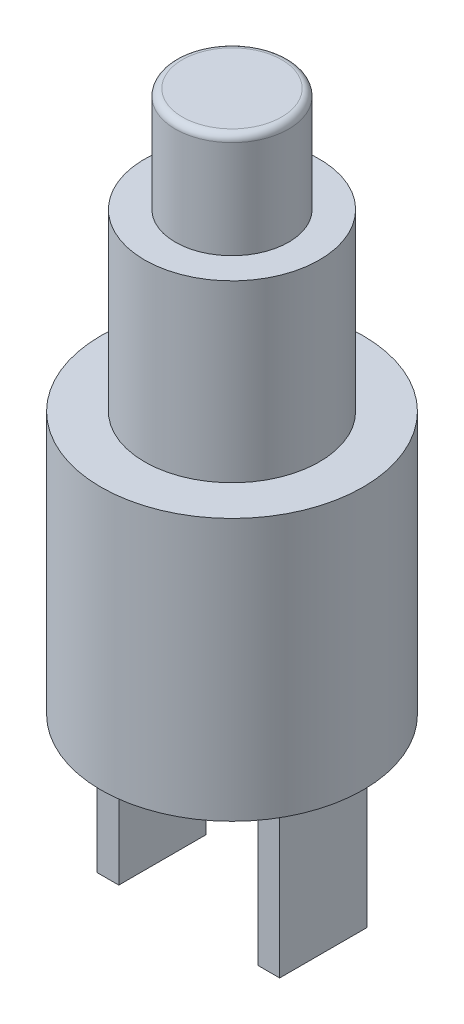
from build123d import *

# Parameters (mm, degrees)
SKETCH1_R           = 4.7625
BOSS_EXTRUDE1_DEPTH = 9.525
SKETCH2_R           = 3.175
BOSS_EXTRUDE2_DEPTH = 6.35
SKETCH3_R           = 2.0574
BOSS_EXTRUDE3_DEPTH = 3.81
SKETCH4_W           = 0.79375
SKETCH4_H           = 3.175
BOSS_EXTRUDE4_DEPTH = 5.842
FILLET1_R           = 0.254


with BuildPart() as part:
    # Sketch1 → Boss-Extrude1 (new body)
    with BuildSketch(Plane(origin=(0, 0, 0), x_dir=(1, 0, 0), z_dir=(0, 1, 0))):
        Circle(SKETCH1_R)
    extrude(amount=-BOSS_EXTRUDE1_DEPTH)

    # Sketch2 → Boss-Extrude2 (add)
    with BuildSketch(Plane(origin=(0, 0, 0), x_dir=(1, 0, 0), z_dir=(0, 1, 0))):
        Circle(SKETCH2_R)
    extrude(amount=BOSS_EXTRUDE2_DEPTH)

    # Sketch3 → Boss-Extrude3 (add)
    with BuildSketch(Plane(origin=(0, 6.35, 0), x_dir=(1, 0, 0), z_dir=(0, 1, 0))):
        Circle(SKETCH3_R)
    extrude(amount=BOSS_EXTRUDE3_DEPTH)

    # Sketch4 → Boss-Extrude4 (add)
    with BuildSketch(Plane.XZ.offset(9.525)):
        with Locations((2.921, 0)):
            Rectangle(SKETCH4_W, SKETCH4_H)
        with Locations((-2.921, 0)):
            Rectangle(SKETCH4_W, SKETCH4_H)
    extrude(amount=BOSS_EXTRUDE4_DEPTH)

    # Fillet1
    fillet1_edges = [part.edges().sort_by_distance(p)[0] for p in [
        (-2.0574, 10.16, 0),
    ]]
    fillet(fillet1_edges, radius=FILLET1_R)


solid = part.part
